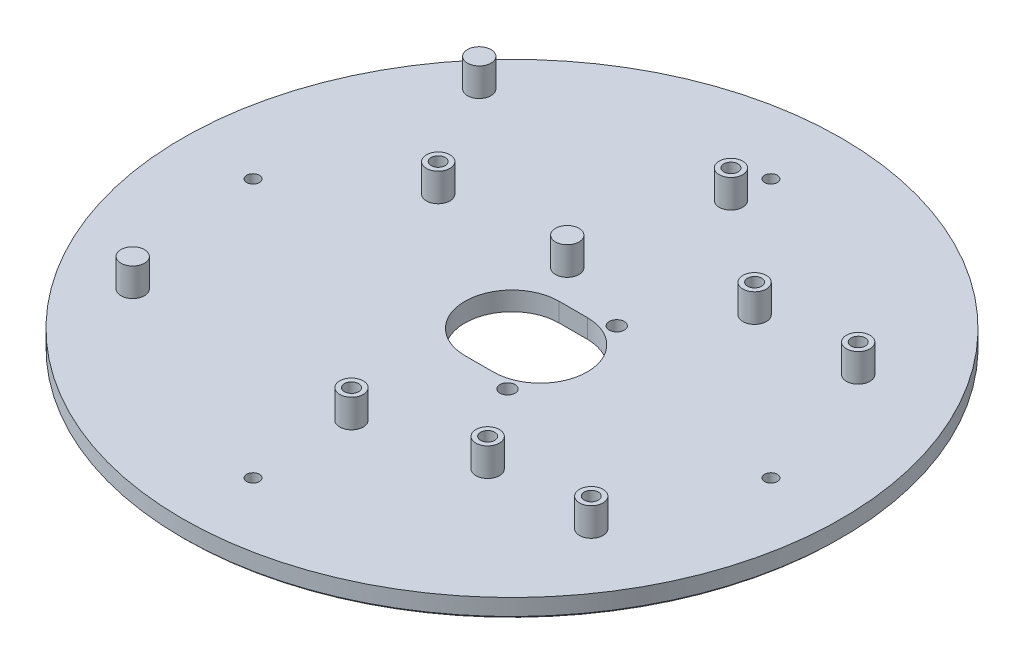
from build123d import *

# Parameters (mm, degrees)
SKIZZE1_R                            = 70
AUFSATZ_LINEAR_AUSTRAGEN1_DEPTH      = 4
SCHNITT_LINEAR_AUSTRAGEN1_REACH      = 6
SKIZZE2_R                            = 2.5
SKIZZE2_R_2                          = 1.5
AUFSATZ_LINEAR_AUSTRAGEN2_DEPTH      = 6
AUFSATZ_LINEAR_AUSTRAGEN2_DEPTH_BACK = 4
SKIZZE4_R                            = 1.5
SKIZZE4_R_2                          = 1.410083192
SCHNITT_LINEAR_AUSTRAGEN2_DEPTH      = 5
FASE1_SIZE                           = 0.5
SCHNITT_LINEAR_AUSTRAGEN3_REACH      = 12
SKIZZE5_R                            = 1.35
SKIZZE6_R                            = 1.6
SCHNITT_LINEAR_AUSTRAGEN4_DEPTH      = 4


with BuildPart() as part:
    # Skizze1 → Aufsatz-Linear austragen1 (new body)
    with BuildSketch(Plane(origin=(0, 0, 0), x_dir=(1, 0, 0), z_dir=(0, 1, 0))):
        Circle(SKIZZE1_R)
    extrude(amount=AUFSATZ_LINEAR_AUSTRAGEN1_DEPTH)

    # Skizze3 → Schnitt-Linear austragen1 (cut, up to next)
    with BuildSketch(Plane.XZ, mode=Mode.PRIVATE) as schnitt_linear_austragen1_sk1:
        with BuildLine():
            Line((6, -10), (0, -10))
            ThreePointArc((0, -10), (-10, 0), (0, 10))
            Line((0, 10), (6, 10))
            ThreePointArc((6, 10), (16, 0), (6, -10))
        make_face()
    schnitt_linear_austragen1_tool1 = extrude(schnitt_linear_austragen1_sk1.sketch, amount=-SCHNITT_LINEAR_AUSTRAGEN1_REACH, mode=Mode.PRIVATE) & part.part
    add(schnitt_linear_austragen1_tool1.solids().sort_by_distance((3, 0, 0))[0], mode=Mode.SUBTRACT)

    # Skizze2 → Aufsatz-Linear austragen2 (add, two sides)
    with BuildSketch(Plane(origin=(0, 4, 0), x_dir=(1, 0, 0), z_dir=(0, 1, 0))) as aufsatz_linear_austragen2_sk:
        with Locations((-47.533988615, 40.571841958)):
            Circle(SKIZZE2_R)
        with Locations((-5.293377745, 17.030303573)):
            Circle(SKIZZE2_R)
        with Locations((-47.533988615, -33.027520141)):
            Circle(SKIZZE2_R)
        with Locations((-32.533187453, 16.85488412)):
            Circle(SKIZZE2_R)
        with Locations((-32.533187453, 16.85488412)):
            Circle(SKIZZE2_R_2, mode=Mode.SUBTRACT)
        with Locations((-0.280707317, 46.779952313)):
            Circle(SKIZZE2_R)
        with Locations((-0.280707317, 46.779952313)):
            Circle(SKIZZE2_R_2, mode=Mode.SUBTRACT)
        with Locations((23.260650032, 28.271453094)):
            Circle(SKIZZE2_R)
        with Locations((23.260650032, 28.271453094)):
            Circle(SKIZZE2_R_2, mode=Mode.SUBTRACT)
        with Locations((45.260650032, 28.271453094)):
            Circle(SKIZZE2_R)
        with Locations((45.260650032, 28.271453094)):
            Circle(SKIZZE2_R_2, mode=Mode.SUBTRACT)
        with Locations((45.260650032, -28.428546906)):
            Circle(SKIZZE2_R)
        with Locations((45.260650032, -28.428546906)):
            Circle(SKIZZE2_R_2, mode=Mode.SUBTRACT)
        with Locations((23.260650032, -28.428546906)):
            Circle(SKIZZE2_R)
        with Locations((23.260650032, -28.428546906)):
            Circle(SKIZZE2_R_2, mode=Mode.SUBTRACT)
        with Locations((-0.152992521, -33.940171336)):
            Circle(SKIZZE2_R)
        with Locations((-0.152992521, -33.940171336)):
            Circle(SKIZZE2_R_2, mode=Mode.SUBTRACT)
    extrude(amount=AUFSATZ_LINEAR_AUSTRAGEN2_DEPTH)
    extrude(aufsatz_linear_austragen2_sk.sketch, amount=-AUFSATZ_LINEAR_AUSTRAGEN2_DEPTH_BACK)

    # Skizze4 → Schnitt-Linear austragen2 (cut, through all)
    with BuildSketch(Plane(origin=(0, 4, 0), x_dir=(1, 0, 0), z_dir=(0, 1, 0))):
        with Locations((-32.533187453, 16.85488412)):
            Circle(SKIZZE4_R)
        with Locations((23.260650032, 28.271453094)):
            Circle(SKIZZE4_R)
        with Locations((45.260650032, 28.271453094)):
            Circle(SKIZZE4_R)
        with Locations((45.260650032, -28.428546906)):
            Circle(SKIZZE4_R)
        with Locations((23.260650032, -28.428546906)):
            Circle(SKIZZE4_R)
        with Locations((-0.152992521, -33.940171336)):
            Circle(SKIZZE4_R)
        with Locations((-0.280707317, 46.779952313)):
            Circle(SKIZZE4_R_2)
    extrude(amount=-SCHNITT_LINEAR_AUSTRAGEN2_DEPTH, mode=Mode.SUBTRACT)

    # Fase1
    fase1_edges = [part.edges().sort_by_distance(p)[0] for p in [
        (-70, 0, 0),
    ]]
    chamfer(fase1_edges, length=FASE1_SIZE)

    # Skizze5 → Schnitt-Linear austragen3 (cut, up to next)
    with BuildSketch(Plane.XZ, mode=Mode.PRIVATE) as schnitt_linear_austragen3_sk1:
        with Locations((-55, 0)):
            Circle(SKIZZE5_R)
    schnitt_linear_austragen3_tool1 = extrude(schnitt_linear_austragen3_sk1.sketch, amount=-SCHNITT_LINEAR_AUSTRAGEN3_REACH, mode=Mode.PRIVATE) & part.part
    add(schnitt_linear_austragen3_tool1.solids().sort_by_distance((-55, 0, 0))[0], mode=Mode.SUBTRACT)
    # Skizze5 → Schnitt-Linear austragen3 (cut, up to next)
    with BuildSketch(Plane.XZ, mode=Mode.PRIVATE) as schnitt_linear_austragen3_sk2:
        with Locations((55, 0)):
            Circle(SKIZZE5_R)
    schnitt_linear_austragen3_tool2 = extrude(schnitt_linear_austragen3_sk2.sketch, amount=-SCHNITT_LINEAR_AUSTRAGEN3_REACH, mode=Mode.PRIVATE) & part.part
    add(schnitt_linear_austragen3_tool2.solids().sort_by_distance((55, 0, 0))[0], mode=Mode.SUBTRACT)
    # Skizze5 → Schnitt-Linear austragen3 (cut, up to next)
    with BuildSketch(Plane.XZ, mode=Mode.PRIVATE) as schnitt_linear_austragen3_sk3:
        with Locations((0, -55)):
            Circle(SKIZZE5_R)
    schnitt_linear_austragen3_tool3 = extrude(schnitt_linear_austragen3_sk3.sketch, amount=-SCHNITT_LINEAR_AUSTRAGEN3_REACH, mode=Mode.PRIVATE) & part.part
    add(schnitt_linear_austragen3_tool3.solids().sort_by_distance((0, 0, -55))[0], mode=Mode.SUBTRACT)
    # Skizze5 → Schnitt-Linear austragen3 (cut, up to next)
    with BuildSketch(Plane.XZ, mode=Mode.PRIVATE) as schnitt_linear_austragen3_sk4:
        with Locations((0, 55)):
            Circle(SKIZZE5_R)
    schnitt_linear_austragen3_tool4 = extrude(schnitt_linear_austragen3_sk4.sketch, amount=-SCHNITT_LINEAR_AUSTRAGEN3_REACH, mode=Mode.PRIVATE) & part.part
    add(schnitt_linear_austragen3_tool4.solids().sort_by_distance((0, 0, 55))[0], mode=Mode.SUBTRACT)

    # Skizze6 → Schnitt-Linear austragen4 (cut)
    with BuildSketch(Plane(origin=(0, 0, 0), x_dir=(-1, 0, 0), z_dir=(0, -1, 0))):
        with Locations((-10.644187298, 11.605236936)):
            Circle(SKIZZE6_R)
        with Locations((-10.644187298, -11.605236936)):
            Circle(SKIZZE6_R)
    extrude(amount=-SCHNITT_LINEAR_AUSTRAGEN4_DEPTH, mode=Mode.SUBTRACT)


solid = part.part
